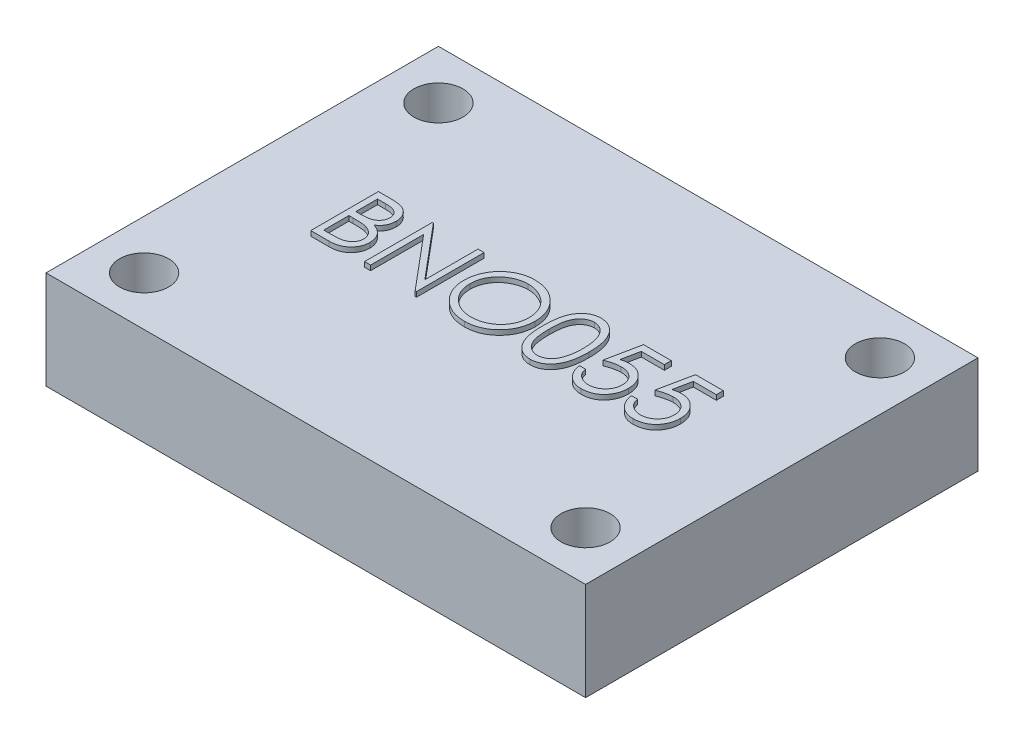
from build123d import *

# Parameters (mm, degrees)
SKETCH1_W           = 27.94
SKETCH1_H           = 20.32
SKETCH1_R           = 1.27
BOSS_EXTRUDE1_DEPTH = 5.08
BOSS_EXTRUDE2_DEPTH = 0.254


with BuildPart() as part:
    # Sketch1 → Boss-Extrude1 (new body)
    with BuildSketch(Plane(origin=(0, 0, 0), x_dir=(1, 0, 0), z_dir=(0, 1, 0))):
        Rectangle(SKETCH1_W, SKETCH1_H)
        with Locations((-11.43, 7.62)):
            Circle(SKETCH1_R, mode=Mode.SUBTRACT)
        with Locations((11.43, 7.62)):
            Circle(SKETCH1_R, mode=Mode.SUBTRACT)
        with Locations((11.43, -7.62)):
            Circle(SKETCH1_R, mode=Mode.SUBTRACT)
        with Locations((-11.43, -7.62)):
            Circle(SKETCH1_R, mode=Mode.SUBTRACT)
    extrude(amount=-BOSS_EXTRUDE1_DEPTH)

    # Sketch2 → Boss-Extrude2 (add)
    with BuildSketch(Plane(origin=(0, 0, 0), x_dir=(1, 0, 0), z_dir=(0, 1, 0))):
        with BuildLine():
            Line((-8.758801587, 1.83922598), (-8.075908959, 1.83922598))
            add(Edge.make_bspline(
                [(-8.075908959, 1.83922598), (-8.042480481, 1.83905023), (-7.97768777, 1.838709582), (-7.883468328, 1.83342645), (-7.795219518, 1.826222781), (-7.712915745, 1.814792688), (-7.636595043, 1.801000911), (-7.566027406, 1.784299095), (-7.501437233, 1.764272481), (-7.424324497, 1.7324262), (-7.336403836, 1.685103031), (-7.241205443, 1.615174466), (-7.159801204, 1.529642003), (-7.089614887, 1.433159348), (-7.033813767, 1.327023576), (-6.99344447, 1.213764387), (-6.967886595, 1.094842645), (-6.96525816, 1.013199467), (-6.963929792, 0.97193832)],
                knots=[0, 0, 0, 0, 0.00010027, 0.000194349, 0.000283026, 0.000365821, 0.000443519, 0.000515622, 0.000583254, 0.00064614, 0.000765662, 0.000881909, 0.000998927, 0.001118415, 0.001238844, 0.00135727, 0.001478274, 0.001601912, 0.001601912, 0.001601912, 0.001601912], degree=3))
            add(Edge.make_bspline(
                [(-6.963929792, 0.97193832), (-6.96502301, 0.933285764), (-6.967171288, 0.857329847), (-6.987714047, 0.746235738), (-7.019874716, 0.640484519), (-7.064579965, 0.540462134), (-7.122681961, 0.44842852), (-7.19154028, 0.363641254), (-7.274617082, 0.289690197), (-7.336860322, 0.248347295), (-7.368477068, 0.227346974)],
                knots=[0, 0, 0, 0, 0.000115857, 0.00022767, 0.000337672, 0.000446877, 0.000555233, 0.000663318, 0.000773539, 0.000887324, 0.000887324, 0.000887324, 0.000887324], degree=3))
            add(Edge.make_bspline(
                [(-7.368477068, 0.227346974), (-7.32871664, 0.212081975), (-7.252645093, 0.18287625), (-7.14795908, 0.131240786), (-7.057764235, 0.075078676), (-6.981367089, 0.013746826), (-6.916029434, -0.052361985), (-6.858976493, -0.124217099), (-6.810295119, -0.202755857), (-6.768582195, -0.287159393), (-6.736033439, -0.376565861), (-6.711657535, -0.470136637), (-6.697690086, -0.567536192), (-6.695702444, -0.633821572), (-6.694699023, -0.667284437)],
                knots=[0, 0, 0, 0, 0.000127722, 0.000244363, 0.000349599, 0.000445847, 0.000537565, 0.000627901, 0.000720503, 0.000814257, 0.000909859, 0.001005428, 0.001103887, 0.001204268, 0.001204268, 0.001204268, 0.001204268], degree=3))
            add(Edge.make_bspline(
                [(-6.694699023, -0.667284437), (-6.695675869, -0.701451309), (-6.697597841, -0.768675587), (-6.711777813, -0.867430721), (-6.73578692, -0.961805668), (-6.768858066, -1.052410851), (-6.81202038, -1.139070985), (-6.864548345, -1.221884249), (-6.927179908, -1.30001858), (-6.997242777, -1.374342203), (-7.076504923, -1.44116999), (-7.162020678, -1.500685697), (-7.254866998, -1.549631759), (-7.353518992, -1.590747781), (-7.459083308, -1.622154979), (-7.571085915, -1.644127553), (-7.689430217, -1.65893259), (-7.770639968, -1.660149795), (-7.812287164, -1.66077402)],
                knots=[0, 0, 0, 0, 0.000102481, 0.000201635, 0.000298562, 0.000394165, 0.000490425, 0.000588455, 0.000687769, 0.000790423, 0.000894381, 0.000998232, 0.001102369, 0.001208616, 0.001318415, 0.001432129, 0.001550749, 0.00167562, 0.00167562, 0.00167562, 0.00167562], degree=3))
            Line((-7.812287164, -1.66077402), (-8.758801587, -1.66077402))
            Line((-8.758801587, -1.66077402), (-8.758801587, 1.83922598))
        make_face()
        with BuildLine():
            Line((-8.444699023, 1.480251621), (-8.444699023, 0.358456749))
            Line((-8.444699023, 0.358456749), (-8.233661363, 0.358456749))
            add(Edge.make_bspline(
                [(-8.233661363, 0.358456749), (-8.202812567, 0.358856672), (-8.143206408, 0.359629405), (-8.056886511, 0.361842922), (-7.976761493, 0.368040965), (-7.90296966, 0.374237228), (-7.835627216, 0.384311815), (-7.774883355, 0.396303938), (-7.719784758, 0.408986843), (-7.656245212, 0.43055633), (-7.584172264, 0.462434005), (-7.50733916, 0.511905841), (-7.43960469, 0.570830195), (-7.382407502, 0.638821156), (-7.335596032, 0.713687342), (-7.303082317, 0.794234223), (-7.281035032, 0.878454355), (-7.279043501, 0.936272607), (-7.278032356, 0.965628224)],
                knots=[0, 0, 0, 0, 9.2559e-05, 0.000178842, 0.000258967, 0.000333616, 0.000400942, 0.000463093, 0.000519379, 0.000570374, 0.000664201, 0.000755025, 0.000843472, 0.000932526, 0.001020669, 0.001107124, 0.001192318, 0.001280185, 0.001280185, 0.001280185, 0.001280185], degree=3))
            add(Edge.make_bspline(
                [(-7.278032356, 0.965628224), (-7.278558536, 0.985053995), (-7.279590696, 1.023159767), (-7.288043999, 1.078709121), (-7.302411573, 1.130952874), (-7.320865866, 1.180606984), (-7.346654555, 1.226118834), (-7.377018019, 1.26906203), (-7.413703709, 1.307974149), (-7.455461021, 1.344343647), (-7.503469644, 1.376588175), (-7.557700936, 1.404828938), (-7.618888613, 1.427569715), (-7.686001468, 1.447485867), (-7.760072556, 1.461474161), (-7.840247109, 1.473127549), (-7.927181828, 1.479060291), (-7.987326931, 1.479845653), (-8.018416972, 1.480251621)],
                knots=[0, 0, 0, 0, 5.8261e-05, 0.000114285, 0.000168029, 0.000220632, 0.000272728, 0.000324483, 0.000378062, 0.000432741, 0.000490301, 0.000551137, 0.000615721, 0.000685833, 0.000760908, 0.00084162, 0.000928788, 0.00102206, 0.00102206, 0.00102206, 0.00102206], degree=3))
            Line((-8.018416972, 1.480251621), (-8.444699023, 1.480251621))
        make_face(mode=Mode.SUBTRACT)
        with BuildLine():
            Line((-8.444699023, -0.00051761), (-8.444699023, -1.301799661))
            Line((-8.444699023, -1.301799661), (-7.997383318, -1.301799661))
            add(Edge.make_bspline(
                [(-7.997383318, -1.301799661), (-7.965364392, -1.301415914), (-7.903652133, -1.300676291), (-7.814550903, -1.298261737), (-7.731967799, -1.292769461), (-7.656279664, -1.284123611), (-7.586669211, -1.274745162), (-7.523971508, -1.262133881), (-7.467678314, -1.247684921), (-7.402404007, -1.225350748), (-7.328900498, -1.190654277), (-7.249689642, -1.138340051), (-7.179263424, -1.076016743), (-7.119458165, -1.003885829), (-7.070445176, -0.925454502), (-7.034789721, -0.842309152), (-7.012798864, -0.755823625), (-7.010136695, -0.696856912), (-7.008801587, -0.667284437)],
                knots=[0, 0, 0, 0, 9.6064e-05, 0.000185151, 0.000267373, 0.000344257, 0.000413665, 0.000478015, 0.000536005, 0.000587888, 0.000684801, 0.000778918, 0.000871787, 0.000965866, 0.001059062, 0.00114827, 0.001236355, 0.001324974, 0.001324974, 0.001324974, 0.001324974], degree=3))
            add(Edge.make_bspline(
                [(-7.008801587, -0.667284437), (-7.009077691, -0.648791096), (-7.009625446, -0.612102714), (-7.017886061, -0.558186895), (-7.029899931, -0.505961022), (-7.045431365, -0.455283281), (-7.068050832, -0.407069905), (-7.094457377, -0.360367345), (-7.125418779, -0.315113866), (-7.173662945, -0.257901613), (-7.243834929, -0.1919846), (-7.343541705, -0.127447097), (-7.456914002, -0.07539929), (-7.539141495, -0.053299814), (-7.581618093, -0.041883796)],
                knots=[0, 0, 0, 0, 5.5429e-05, 0.000109963, 0.000163198, 0.000216191, 0.000268588, 0.000322593, 0.000377046, 0.000432793, 0.000546889, 0.000664343, 0.000787646, 0.000919405, 0.000919405, 0.000919405, 0.000919405], degree=3))
            add(Edge.make_bspline(
                [(-7.581618093, -0.041883796), (-7.598647189, -0.038428712), (-7.635569782, -0.030937377), (-7.695777362, -0.023029674), (-7.764513231, -0.015984614), (-7.841936108, -0.010773456), (-7.928143949, -0.005386912), (-8.023320868, -0.003292091), (-8.127078183, -0.000792831), (-8.199070555, -0.000611697), (-8.23646585, -0.00051761)],
                knots=[0, 0, 0, 0, 5.2115e-05, 0.000112995, 0.000182062, 0.000259389, 0.000345767, 0.00044116, 0.000544948, 0.000657129, 0.000657129, 0.000657129, 0.000657129], degree=3))
            Line((-8.23646585, -0.00051761), (-8.444699023, -0.00051761))
        make_face(mode=Mode.SUBTRACT)
        Polygon((-5.976750305, -1.66077402), (-5.976750305, 1.83922598), (-5.910844856, 1.83922598), (-3.598545177, -0.915481552), (-3.598545177, 1.83922598), (-3.284442613, 1.83922598), (-3.284442613, -1.66077402), (-3.355957036, -1.66077402), (-5.662647741, 1.087623416), (-5.662647741, -1.66077402), align=None)
        with BuildLine():
            add(Edge.make_bspline(
                [(-0.749186202, 1.92896957), (-0.684378096, 1.92732809), (-0.557089629, 1.924104089), (-0.370014732, 1.899424986), (-0.191419636, 1.856729596), (-0.019849498, 1.799866613), (0.142643479, 1.724012228), (0.297282371, 1.63232708), (0.443699245, 1.523850621), (0.579920627, 1.399421394), (0.704577577, 1.26403794), (0.814403463, 1.11956003), (0.906445757, 0.966861228), (0.982031544, 0.806400397), (1.041330154, 0.638540429), (1.082249198, 0.462386426), (1.108387348, 0.279079736), (1.111443125, 0.154052872), (1.112993285, 0.090628224)],
                knots=[0, 0, 0, 0, 0.000194393, 0.000381804, 0.00056479, 0.000744601, 0.000923091, 0.001101652, 0.001283106, 0.001468738, 0.001654324, 0.001834514, 0.002012231, 0.002188181, 0.002365797, 0.002545211, 0.002729936, 0.002920126, 0.002920126, 0.002920126, 0.002920126], degree=3))
            add(Edge.make_bspline(
                [(1.112993285, 0.090628224), (1.111443352, 0.027670777), (1.108388256, -0.096425643), (1.082219478, -0.278569087), (1.041178478, -0.453659784), (0.982582212, -0.621405437), (0.907356734, -0.781983), (0.814701563, -0.934969954), (0.705560352, -1.080416453), (0.581353501, -1.216729118), (0.445952459, -1.341726589), (0.300722192, -1.450645464), (0.148928872, -1.544369589), (-0.011380836, -1.619153263), (-0.178080873, -1.678925183), (-0.352663196, -1.719677813), (-0.53430975, -1.745964857), (-0.658180754, -1.748983373), (-0.72114133, -1.75051761)],
                knots=[0, 0, 0, 0, 0.000188789, 0.000372126, 0.000550857, 0.00072758, 0.000904164, 0.001081881, 0.001263191, 0.001448823, 0.00163441, 0.001815159, 0.001992641, 0.002168591, 0.002344885, 0.002522934, 0.002705576, 0.002894365, 0.002894365, 0.002894365, 0.002894365], degree=3))
            add(Edge.make_bspline(
                [(-0.72114133, -1.75051761), (-0.784565649, -1.748968223), (-0.909591865, -1.745913969), (-1.093128901, -1.719732564), (-1.269406645, -1.67879126), (-1.437920996, -1.620281824), (-1.598765925, -1.544664593), (-1.752256008, -1.452460214), (-1.897775155, -1.343053073), (-2.034116902, -1.218886499), (-2.1588661, -1.083714947), (-2.267625476, -0.938880691), (-2.359850589, -0.787225235), (-2.435213922, -0.628327711), (-2.494878381, -0.462956268), (-2.535583199, -0.290007791), (-2.561919151, -0.110468285), (-2.564953998, 0.011774614), (-2.566493895, 0.073801301)],
                knots=[0, 0, 0, 0, 0.00019019, 0.000374915, 0.000555011, 0.000732396, 0.00090898, 0.001087298, 0.001268608, 0.00145424, 0.001639827, 0.001819595, 0.001996712, 0.002171394, 0.002346367, 0.002523053, 0.002703612, 0.002889599, 0.002889599, 0.002889599, 0.002889599], degree=3))
            add(Edge.make_bspline(
                [(-2.566493895, 0.073801301), (-2.565959259, 0.11543397), (-2.564896733, 0.198174093), (-2.55210504, 0.321040693), (-2.533543339, 0.441931351), (-2.506941427, 0.560502299), (-2.47214976, 0.676463284), (-2.431097732, 0.790614047), (-2.380957887, 0.90179777), (-2.324277239, 1.010541162), (-2.261015431, 1.115149068), (-2.191139681, 1.214028651), (-2.117104313, 1.308009648), (-2.035940919, 1.394656652), (-1.950324474, 1.476490308), (-1.858866096, 1.552253025), (-1.762123851, 1.622627976), (-1.659681472, 1.686048317), (-1.554063197, 1.743407452), (-1.445186419, 1.792629303), (-1.334529848, 1.834875364), (-1.2215752, 1.869116189), (-1.106622428, 1.896148225), (-0.989420643, 1.914555579), (-0.870063217, 1.927379897), (-0.789651898, 1.928437399), (-0.749186202, 1.92896957)],
                knots=[0, 0, 0, 0, 0.000124849, 0.000248123, 0.000370193, 0.00049164, 0.000612319, 0.000733199, 0.000855287, 0.000977905, 0.001100913, 0.001221706, 0.001340948, 0.001459521, 0.001577551, 0.001696047, 0.001815534, 0.001936153, 0.002057243, 0.002175846, 0.002294342, 0.002412335, 0.002529682, 0.00264829, 0.002768075, 0.00288942, 0.00288942, 0.00288942, 0.00288942], degree=3))
        make_face()
        with BuildLine():
            add(Edge.make_bspline(
                [(-0.733761523, 1.569995211), (-0.766976156, 1.569590321), (-0.833087889, 1.568784411), (-0.931372426, 1.558168695), (-1.028364359, 1.543038806), (-1.124083722, 1.521457285), (-1.218130011, 1.492053233), (-1.311379852, 1.458212325), (-1.402982906, 1.416991234), (-1.492636764, 1.37041853), (-1.579551839, 1.318869609), (-1.66156454, 1.261897842), (-1.738887184, 1.200839287), (-1.811330451, 1.13555145), (-1.878681623, 1.065701848), (-1.942266325, 0.992349412), (-1.999535906, 0.913397521), (-2.052021483, 0.830987114), (-2.098989323, 0.745225533), (-2.140754678, 0.657015671), (-2.174918687, 0.565637984), (-2.202781063, 0.472083826), (-2.225880874, 0.376501367), (-2.240514798, 0.278165518), (-2.251247158, 0.177570406), (-2.252007003, 0.109588552), (-2.25239133, 0.075203544)],
                knots=[0, 0, 0, 0, 9.9599e-05, 0.000198245, 0.000296222, 0.00039402, 0.00049227, 0.000591646, 0.000691452, 0.000793368, 0.000894612, 0.000994383, 0.001092713, 0.00119001, 0.001286696, 0.001383657, 0.001480979, 0.001579008, 0.001676595, 0.001774142, 0.001871547, 0.001968922, 0.002066879, 0.00216624, 0.00226698, 0.002370083, 0.002370083, 0.002370083, 0.002370083], degree=3))
            add(Edge.make_bspline(
                [(-2.25239133, 0.075203544), (-2.251116469, 0.024641323), (-2.248608421, -0.074830207), (-2.226650851, -0.220598351), (-2.192828876, -0.360686637), (-2.14297151, -0.494328546), (-2.080620895, -0.622672829), (-2.003594005, -0.744580934), (-1.912334919, -0.860085808), (-1.808671393, -0.968381077), (-1.695348686, -1.067226882), (-1.575015956, -1.15399029), (-1.448962349, -1.22740054), (-1.316859146, -1.287205612), (-1.179411607, -1.33459535), (-1.035734056, -1.367073981), (-0.886783596, -1.388449437), (-0.785252941, -1.390502193), (-0.733761523, -1.391543251)],
                knots=[0, 0, 0, 0, 0.000151605, 0.000298253, 0.000441263, 0.000583229, 0.000725274, 0.000868635, 0.001014928, 0.001166177, 0.001317744, 0.00146543, 0.001610576, 0.001754594, 0.001899821, 0.002045914, 0.002195936, 0.002350312, 0.002350312, 0.002350312, 0.002350312], degree=3))
            add(Edge.make_bspline(
                [(-0.733761523, -1.391543251), (-0.699152021, -1.391067746), (-0.630510985, -1.390124678), (-0.528415462, -1.380626002), (-0.428159251, -1.365394132), (-0.329882971, -1.343463477), (-0.233698159, -1.31601627), (-0.139203356, -1.283408542), (-0.047405066, -1.242727338), (0.042854772, -1.197779387), (0.129251013, -1.146539229), (0.211726546, -1.09150108), (0.288202526, -1.030532459), (0.360591597, -0.966214646), (0.428219286, -0.897250799), (0.49062827, -0.823730577), (0.547608402, -0.74518992), (0.600074049, -0.662904514), (0.646877312, -0.576908261), (0.687656411, -0.488378583), (0.722252527, -0.397533474), (0.750181031, -0.304241902), (0.772066493, -0.208681054), (0.787146413, -0.110722975), (0.797694852, -0.010563633), (0.798489929, 0.057180223), (0.798890721, 0.091329345)],
                knots=[0, 0, 0, 0, 0.000103804, 0.000205874, 0.000307314, 0.000407849, 0.000507719, 0.000607281, 0.000707445, 0.000808723, 0.000909609, 0.001008589, 0.001105934, 0.001202762, 0.001298946, 0.001395452, 0.001491794, 0.001589823, 0.001688026, 0.001785277, 0.001882027, 0.001979402, 0.0020772, 0.002175869, 0.002276609, 0.002379011, 0.002379011, 0.002379011, 0.002379011], degree=3))
            add(Edge.make_bspline(
                [(0.798890721, 0.091329345), (0.798489608, 0.12524485), (0.797693926, 0.1925225), (0.787151452, 0.291983318), (0.772050561, 0.38923653), (0.750287853, 0.483900333), (0.7222377, 0.575998858), (0.687650369, 0.665445605), (0.64686507, 0.752573801), (0.600056845, 0.837168098), (0.547441022, 0.918342836), (0.489946779, 0.995945248), (0.42658143, 1.068517989), (0.359155406, 1.137852683), (0.28598452, 1.202470573), (0.207400226, 1.262393094), (0.124356548, 1.319066368), (0.036429313, 1.37019193), (-0.054314641, 1.417406162), (-0.147428599, 1.457857166), (-0.241857698, 1.492229285), (-0.337361811, 1.52154625), (-0.434744789, 1.54295428), (-0.533348618, 1.55818233), (-0.633036876, 1.568780716), (-0.700080096, 1.569589095), (-0.733761523, 1.569995211)],
                knots=[0, 0, 0, 0, 0.000101701, 0.000201743, 0.00029972, 0.000396835, 0.000492868, 0.000588308, 0.000684288, 0.000781261, 0.000878109, 0.000974304, 0.001070733, 0.001166917, 0.001264269, 0.001363274, 0.001463228, 0.001565678, 0.001668217, 0.001769947, 0.001869982, 0.001969573, 0.002069423, 0.002168785, 0.002268827, 0.002369827, 0.002369827, 0.002369827, 0.002369827], degree=3))
        make_face(mode=Mode.SUBTRACT)
        with BuildLine():
            add(Edge.make_bspline(
                [(1.516839439, 0.087823736), (1.517167457, 0.143921124), (1.517804637, 0.252891108), (1.524893058, 0.41167575), (1.5366684, 0.560636039), (1.552805773, 0.699779106), (1.572443753, 0.82914087), (1.59865924, 0.948375627), (1.628472042, 1.058035234), (1.663024488, 1.158477282), (1.702012277, 1.251054985), (1.744446538, 1.337480187), (1.792011332, 1.417622119), (1.841988245, 1.492759909), (1.896400317, 1.561663604), (1.953699107, 1.625306267), (2.016120984, 1.682217017), (2.081543992, 1.734063319), (2.150560456, 1.779512791), (2.221203123, 1.81954553), (2.293958228, 1.853745397), (2.369024411, 1.880635833), (2.445726969, 1.90284668), (2.524334036, 1.918035627), (2.6049754, 1.927592536), (2.659406835, 1.928506204), (2.687011714, 1.92896957)],
                knots=[0, 0, 0, 0, 0.000168282, 0.000326891, 0.000476705, 0.00061646, 0.000747059, 0.00086904, 0.000982494, 0.001087814, 0.001187428, 0.001283689, 0.001376399, 0.001466822, 0.001554203, 0.001639568, 0.001723424, 0.001807301, 0.001889751, 0.001971063, 0.002050735, 0.002130583, 0.002210036, 0.002290062, 0.002370508, 0.002453288, 0.002453288, 0.002453288, 0.002453288], degree=3))
            add(Edge.make_bspline(
                [(2.687011714, 1.92896957), (2.714847193, 1.928481755), (2.770203202, 1.927511644), (2.852043577, 1.918187701), (2.931993259, 1.902716578), (3.009711397, 1.880795603), (3.085836384, 1.853599927), (3.159772792, 1.81951281), (3.231979873, 1.779833942), (3.301310161, 1.733210065), (3.368524776, 1.681227789), (3.431972739, 1.62246512), (3.491659825, 1.557515401), (3.54833513, 1.487073537), (3.600390728, 1.409788452), (3.64996416, 1.327004342), (3.694336196, 1.237273477), (3.737070871, 1.14209301), (3.773957858, 1.038829351), (3.807224103, 0.92806459), (3.834103071, 0.808490403), (3.856492344, 0.680734158), (3.87383724, 0.544326675), (3.886469882, 0.399560359), (3.893142967, 0.246339969), (3.894399668, 0.14158212), (3.895044567, 0.087823736)],
                knots=[0, 0, 0, 0, 8.3481e-05, 0.000166017, 0.000246731, 0.000327534, 0.000408041, 0.000488986, 0.000571522, 0.000654944, 0.000739373, 0.000826202, 0.000914021, 0.001003809, 0.001097153, 0.001193347, 0.001293057, 0.001397277, 0.001506176, 0.001621751, 0.001744038, 0.001873599, 0.002010742, 0.002156422, 0.002309427, 0.002470709, 0.002470709, 0.002470709, 0.002470709], degree=3))
            add(Edge.make_bspline(
                [(3.895044567, 0.087823736), (3.894392982, 0.034299828), (3.893123396, -0.069989323), (3.88654469, -0.222520299), (3.873586059, -0.366518342), (3.85737607, -0.502328804), (3.834925107, -0.629386423), (3.807319941, -0.748130872), (3.776669618, -0.859074943), (3.738834824, -0.961309755), (3.697424114, -1.056261478), (3.652368918, -1.144928626), (3.604099091, -1.228094919), (3.551510346, -1.305094666), (3.495456933, -1.376473323), (3.434739144, -1.440970946), (3.371068559, -1.500141618), (3.303656144, -1.552793245), (3.233244592, -1.59887805), (3.161285515, -1.6400919), (3.086502132, -1.673324595), (3.010589179, -1.701859636), (2.932460813, -1.723660088), (2.852214423, -1.738733943), (2.770258187, -1.749305792), (2.714856621, -1.750112272), (2.687011714, -1.75051761)],
                knots=[0, 0, 0, 0, 0.000160581, 0.000312886, 0.000457868, 0.000594226, 0.000723097, 0.000844701, 0.000959884, 0.001068125, 0.001171421, 0.001270505, 0.001366343, 0.001459687, 0.001550023, 0.00163832, 0.001725149, 0.001810562, 0.001894568, 0.001977446, 0.00205903, 0.002139777, 0.00222058, 0.002301983, 0.002384599, 0.00246808, 0.00246808, 0.00246808, 0.00246808], degree=3))
            add(Edge.make_bspline(
                [(2.687011714, -1.75051761), (2.6594076, -1.750051254), (2.604977676, -1.749131692), (2.52432525, -1.739617961), (2.446042807, -1.724322458), (2.369744053, -1.702905854), (2.295037538, -1.676691017), (2.222941251, -1.642537334), (2.152653567, -1.603203265), (2.084362011, -1.558407843), (2.01934985, -1.50708616), (1.957251245, -1.450321871), (1.899626226, -1.38669846), (1.84599213, -1.317220537), (1.795018042, -1.242527295), (1.748128669, -1.161598922), (1.704757815, -1.074756311), (1.665114324, -0.9814384), (1.62996566, -0.880283473), (1.598917952, -0.770134294), (1.574403795, -0.650018658), (1.55342084, -0.520901291), (1.536496456, -0.38222736), (1.524942131, -0.233921582), (1.517800816, -0.076076373), (1.517165746, 0.032193401), (1.516839439, 0.087823736)],
                knots=[0, 0, 0, 0, 8.278e-05, 0.000163226, 0.000243252, 0.00032184, 0.00040079, 0.000480463, 0.00056082, 0.000642298, 0.000725191, 0.000809047, 0.000894412, 0.000982346, 0.001072188, 0.001165503, 0.001262704, 0.001363236, 0.001469448, 0.001583766, 0.001706286, 0.001836995, 0.001976138, 0.002125253, 0.002283161, 0.002450041, 0.002450041, 0.002450041, 0.002450041], degree=3))
        make_face()
        with BuildLine():
            add(Edge.make_bspline(
                [(1.830942003, 0.08922598), (1.83106145, 0.042477281), (1.831293273, -0.048252764), (1.837349474, -0.180096025), (1.845599706, -0.303066353), (1.856241003, -0.41731989), (1.872043952, -0.522469902), (1.889750739, -0.619239585), (1.911298829, -0.707116823), (1.936793847, -0.786704633), (1.965832944, -0.859353702), (1.997538807, -0.926954917), (2.03159953, -0.990306853), (2.069718681, -1.048840462), (2.111233744, -1.102746626), (2.155207003, -1.152979458), (2.203279587, -1.197776439), (2.26978333, -1.251503294), (2.357579804, -1.307022428), (2.46820026, -1.355368518), (2.581868711, -1.385750974), (2.659019961, -1.38961473), (2.697528541, -1.391543251)],
                knots=[0, 0, 0, 0, 0.000140231, 0.000272162, 0.000395845, 0.00050998, 0.000616273, 0.00071473, 0.000805025, 0.000887508, 0.000965234, 0.00103957, 0.001111417, 0.001180842, 0.001248855, 0.001315406, 0.001380877, 0.0014457, 0.001571746, 0.00169106, 0.001806864, 0.001922266, 0.001922266, 0.001922266, 0.001922266], degree=3))
            add(Edge.make_bspline(
                [(2.697528541, -1.391543251), (2.736286213, -1.38994547), (2.813721536, -1.386753207), (2.926855331, -1.35595447), (3.036685601, -1.30948493), (3.122757542, -1.254537425), (3.188240085, -1.202209095), (3.235157075, -1.157594447), (3.278219124, -1.10763858), (3.319061199, -1.053739284), (3.356520274, -0.9948668), (3.390583412, -0.931304224), (3.421666759, -0.862875047), (3.439375805, -0.815105307), (3.448429984, -0.790681873)],
                knots=[0, 0, 0, 0, 0.000116044, 0.000231848, 0.000349318, 0.000472837, 0.000536674, 0.000600645, 0.000666733, 0.000734322, 0.000803367, 0.000875831, 0.000950509, 0.001028633, 0.001028633, 0.001028633, 0.001028633], degree=3))
            add(Edge.make_bspline(
                [(3.448429984, -0.790681873), (3.458981751, -0.759452133), (3.480406365, -0.696042369), (3.50801814, -0.597678717), (3.529763539, -0.494475953), (3.549326904, -0.387050836), (3.56267996, -0.274611135), (3.573427774, -0.157504751), (3.579758461, -0.035643389), (3.580543212, 0.047151602), (3.580942003, 0.08922598)],
                knots=[0, 0, 0, 0, 9.8886e-05, 0.00020078, 0.000306259, 0.000415188, 0.00052824, 0.000645799, 0.000767957, 0.000894177, 0.000894177, 0.000894177, 0.000894177], degree=3))
            add(Edge.make_bspline(
                [(3.580942003, 0.08922598), (3.580391814, 0.131293553), (3.579315526, 0.213586717), (3.575201538, 0.334104898), (3.564577964, 0.448572659), (3.552778845, 0.557483132), (3.535381624, 0.660233434), (3.516623817, 0.75768374), (3.491422605, 0.848626764), (3.46450283, 0.934486346), (3.433692434, 1.014287001), (3.3997767, 1.088400787), (3.363554941, 1.157185512), (3.324212701, 1.220452453), (3.282217017, 1.278484996), (3.236459468, 1.330119591), (3.188755095, 1.376956559), (3.12193791, 1.430419128), (3.03446362, 1.484930823), (2.925617973, 1.535096583), (2.812347328, 1.563904876), (2.735773874, 1.567966563), (2.697528541, 1.569995211)],
                knots=[0, 0, 0, 0, 0.000126219, 0.000246912, 0.000361616, 0.00047102, 0.00057545, 0.000674176, 0.000768567, 0.000858368, 0.000944043, 0.001024988, 0.001102772, 0.001177091, 0.00124833, 0.001317386, 0.001383826, 0.001448649, 0.001573728, 0.001692043, 0.001806995, 0.001921698, 0.001921698, 0.001921698, 0.001921698], degree=3))
            add(Edge.make_bspline(
                [(2.697528541, 1.569995211), (2.658817949, 1.567963764), (2.581326244, 1.56389717), (2.466878289, 1.535203916), (2.357173937, 1.485190951), (2.269930963, 1.430238578), (2.203067176, 1.377900267), (2.155984483, 1.332513813), (2.11183831, 1.282867558), (2.07117061, 1.228465643), (2.033081327, 1.170000276), (1.998100315, 1.107011511), (1.966582985, 1.039180147), (1.937498449, 0.966563712), (1.911925661, 0.886982767), (1.890831697, 0.799213774), (1.871344644, 0.702751882), (1.857549375, 0.597032374), (1.84528562, 0.482750221), (1.837404272, 0.359472902), (1.831273014, 0.227408522), (1.83105455, 0.136209363), (1.830942003, 0.08922598)],
                knots=[0, 0, 0, 0, 0.000116101, 0.000232413, 0.000351368, 0.000476447, 0.000540832, 0.000605795, 0.000672346, 0.000739935, 0.00080936, 0.000881545, 0.00095588, 0.001033607, 0.001116089, 0.001206384, 0.001304286, 0.001411174, 0.001526077, 0.001649061, 0.001781692, 0.001922624, 0.001922624, 0.001922624, 0.001922624], degree=3))
        make_face(mode=Mode.SUBTRACT)
        with BuildLine():
            Line((6.40786508, 1.83922598), (6.40786508, 1.480251621))
            Line((6.40786508, 1.480251621), (5.217360272, 1.480251621))
            Line((5.217360272, 1.480251621), (5.028758509, 0.559678704))
            add(Edge.make_bspline(
                [(5.028758509, 0.559678704), (5.065814384, 0.569908976), (5.137604279, 0.58972851), (5.24356414, 0.61173428), (5.344156344, 0.624999724), (5.409431714, 0.626811035), (5.441018125, 0.627687518)],
                knots=[0, 0, 0, 0, 0.000115302, 0.000223379, 0.000324431, 0.000419176, 0.000419176, 0.000419176, 0.000419176], degree=3))
            add(Edge.make_bspline(
                [(5.441018125, 0.627687518), (5.480101864, 0.626841583), (5.556950262, 0.625178262), (5.669389209, 0.609206412), (5.776722102, 0.584066498), (5.878724472, 0.548945976), (5.975585023, 0.504036243), (6.066412584, 0.447936302), (6.152570497, 0.382402971), (6.232513091, 0.307057959), (6.305037399, 0.224136343), (6.368803389, 0.134978472), (6.422965979, 0.040450809), (6.466526734, -0.060349799), (6.501311068, -0.166308953), (6.524463063, -0.278541535), (6.539879772, -0.395989655), (6.541602159, -0.476294225), (6.542480464, -0.517244373)],
                knots=[0, 0, 0, 0, 0.00011719, 0.000230425, 0.000339944, 0.000447481, 0.000553499, 0.000659556, 0.000767111, 0.000877722, 0.000988528, 0.001097091, 0.001206056, 0.001314692, 0.001425996, 0.001539995, 0.001658004, 0.001780798, 0.001780798, 0.001780798, 0.001780798], degree=3))
            add(Edge.make_bspline(
                [(6.542480464, -0.517244373), (6.541815389, -0.545766593), (6.540494226, -0.60242558), (6.533775639, -0.686569781), (6.520839923, -0.768932614), (6.503472199, -0.849525006), (6.480929781, -0.928194378), (6.453640727, -1.005165906), (6.420244699, -1.079960513), (6.383613324, -1.153285908), (6.342366846, -1.223484415), (6.296588339, -1.289133402), (6.248222847, -1.351217683), (6.196181462, -1.409071416), (6.139980467, -1.462314434), (6.0803005, -1.511262716), (6.017617781, -1.556744046), (5.950962539, -1.596912241), (5.881820056, -1.633875197), (5.809191839, -1.664198735), (5.734731138, -1.691309263), (5.657366262, -1.71291879), (5.57727245, -1.729851345), (5.494317674, -1.741351945), (5.408937004, -1.749728383), (5.351061992, -1.75025274), (5.32182742, -1.75051761)],
                knots=[0, 0, 0, 0, 8.5583e-05, 0.000170009, 0.000253005, 0.000335518, 0.000417186, 0.000498352, 0.000580291, 0.000662755, 0.000744161, 0.000824288, 0.000902692, 0.000980133, 0.001057498, 0.001134702, 0.00121156, 0.001289599, 0.001368002, 0.001446531, 0.001525481, 0.001605609, 0.001687289, 0.001770875, 0.001856759, 0.001944425, 0.001944425, 0.001944425, 0.001944425], degree=3))
            add(Edge.make_bspline(
                [(5.32182742, -1.75051761), (5.286953239, -1.749826772), (5.218342408, -1.74846763), (5.117821841, -1.734249144), (5.021107235, -1.713885228), (4.928977134, -1.683248958), (4.84060587, -1.644861663), (4.757183153, -1.596345492), (4.676577377, -1.541366388), (4.60206534, -1.476486035), (4.532909226, -1.405570353), (4.471002718, -1.328612712), (4.415869141, -1.24688327), (4.368391394, -1.159985116), (4.327893373, -1.068146585), (4.296078384, -0.971023584), (4.270400029, -0.86912358), (4.259536609, -0.79897007), (4.254018926, -0.763338123)],
                knots=[0, 0, 0, 0, 0.000104552, 0.000205693, 0.000304023, 0.000400691, 0.00049644, 0.000592535, 0.000689779, 0.000788716, 0.000888377, 0.000986596, 0.001084603, 0.001183757, 0.001283279, 0.001385267, 0.001490017, 0.001598135, 0.001598135, 0.001598135, 0.001598135], degree=3))
            Line((4.254018926, -0.763338123), (4.56812149, -0.763338123))
            add(Edge.make_bspline(
                [(4.56812149, -0.763338123), (4.575850047, -0.796714575), (4.590704764, -0.86086597), (4.623310513, -0.950997311), (4.663176388, -1.031316535), (4.710580736, -1.102886118), (4.767130767, -1.165295115), (4.831660196, -1.220912177), (4.904007919, -1.271087307), (4.984401149, -1.312910074), (5.069214228, -1.348578827), (5.157981438, -1.372330522), (5.248285784, -1.389031415), (5.309364155, -1.390703176), (5.340056586, -1.391543251)],
                knots=[0, 0, 0, 0, 0.000102709, 0.000197412, 0.000286774, 0.000371169, 0.000454082, 0.000538572, 0.000626283, 0.000717552, 0.000809994, 0.00090168, 0.00099274, 0.001084718, 0.001084718, 0.001084718, 0.001084718], degree=3))
            add(Edge.make_bspline(
                [(5.340056586, -1.391543251), (5.370015031, -1.390722473), (5.429003453, -1.389106354), (5.515814839, -1.376667342), (5.599627714, -1.357509771), (5.67961507, -1.328839916), (5.75717661, -1.293995198), (5.83035038, -1.249280122), (5.901253258, -1.197820103), (5.967681391, -1.138863473), (6.02852084, -1.073893779), (6.082276962, -1.004416385), (6.127053875, -0.930299539), (6.164787984, -0.852826386), (6.193441283, -0.771147829), (6.213882264, -0.685646654), (6.225885323, -0.596111673), (6.227536503, -0.535042364), (6.2283779, -0.503923058)],
                knots=[0, 0, 0, 0, 8.9842e-05, 0.0001769, 0.000262612, 0.000347317, 0.000431396, 0.000517249, 0.000604055, 0.000693954, 0.000783242, 0.000870748, 0.000956963, 0.001042571, 0.001128832, 0.00121607, 0.001305907, 0.001399251, 0.001399251, 0.001399251, 0.001399251], degree=3))
            add(Edge.make_bspline(
                [(6.2283779, -0.503923058), (6.227719421, -0.475847307), (6.226430541, -0.420893018), (6.215899971, -0.340493811), (6.197582998, -0.264420769), (6.172159118, -0.192306535), (6.139879611, -0.124083093), (6.100433298, -0.059680033), (6.0530799, 5.3801e-05), (5.998988012, 0.055146354), (5.939729971, 0.105991229), (5.874286228, 0.149335316), (5.804026301, 0.185799233), (5.729796702, 0.217267232), (5.649831803, 0.239867977), (5.565715171, 0.256835862), (5.476538463, 0.266651225), (5.415567775, 0.268013114), (5.384227259, 0.26871316)],
                knots=[0, 0, 0, 0, 8.4208e-05, 0.000164824, 0.000242709, 0.000318547, 0.000393815, 0.000468731, 0.000544614, 0.00062196, 0.000700062, 0.000778428, 0.000856831, 0.000937299, 0.001019835, 0.001105635, 0.00119452, 0.001288536, 0.001288536, 0.001288536, 0.001288536], degree=3))
            add(Edge.make_bspline(
                [(5.384227259, 0.26871316), (5.35709833, 0.268132568), (5.301083975, 0.266933795), (5.215161148, 0.258107298), (5.124869425, 0.243868004), (5.03055493, 0.224281756), (4.931934422, 0.198650679), (4.829216021, 0.167936179), (4.722183754, 0.13121418), (4.65006603, 0.103481966), (4.612993285, 0.08922598)],
                knots=[0, 0, 0, 0, 8.1378e-05, 0.000168026, 0.000258858, 0.000355524, 0.000456875, 0.000564457, 0.000677092, 0.000796243, 0.000796243, 0.000796243, 0.000796243], degree=3))
            Line((4.612993285, 0.08922598), (4.971967644, 1.83922598))
            Line((4.971967644, 1.83922598), (6.40786508, 1.83922598))
        make_face()
        with BuildLine():
            Line((9.100172772, 1.83922598), (9.100172772, 1.480251621))
            Line((9.100172772, 1.480251621), (7.909667964, 1.480251621))
            Line((7.909667964, 1.480251621), (7.721066202, 0.559678704))
            add(Edge.make_bspline(
                [(7.721066202, 0.559678704), (7.758122076, 0.569908976), (7.829911972, 0.58972851), (7.935871833, 0.61173428), (8.036464036, 0.624999724), (8.101739407, 0.626811035), (8.133325817, 0.627687518)],
                knots=[0, 0, 0, 0, 0.000115302, 0.000223379, 0.000324431, 0.000419176, 0.000419176, 0.000419176, 0.000419176], degree=3))
            add(Edge.make_bspline(
                [(8.133325817, 0.627687518), (8.172409557, 0.626841583), (8.249257954, 0.625178262), (8.361696901, 0.609206412), (8.469029794, 0.584066498), (8.571032164, 0.548945976), (8.667892715, 0.504036243), (8.758720276, 0.447936302), (8.844878189, 0.382402971), (8.924820783, 0.307057959), (8.997345092, 0.224136343), (9.061111081, 0.134978472), (9.115273672, 0.040450809), (9.158834426, -0.060349799), (9.193618761, -0.166308953), (9.216770756, -0.278541535), (9.232187465, -0.395989655), (9.233909851, -0.476294225), (9.234788157, -0.517244373)],
                knots=[0, 0, 0, 0, 0.00011719, 0.000230425, 0.000339944, 0.000447481, 0.000553499, 0.000659556, 0.000767111, 0.000877722, 0.000988528, 0.001097091, 0.001206056, 0.001314692, 0.001425996, 0.001539995, 0.001658004, 0.001780798, 0.001780798, 0.001780798, 0.001780798], degree=3))
            add(Edge.make_bspline(
                [(9.234788157, -0.517244373), (9.234123081, -0.545766593), (9.232801919, -0.60242558), (9.226083331, -0.686569781), (9.213147615, -0.768932614), (9.195779891, -0.849525006), (9.173237473, -0.928194378), (9.145948419, -1.005165906), (9.112552392, -1.079960513), (9.075921016, -1.153285908), (9.034674538, -1.223484415), (8.988896031, -1.289133402), (8.94053054, -1.351217683), (8.888489154, -1.409071416), (8.832288159, -1.462314434), (8.772608192, -1.511262716), (8.709925473, -1.556744046), (8.643270231, -1.596912241), (8.574127748, -1.633875197), (8.501499531, -1.664198735), (8.42703883, -1.691309263), (8.349673955, -1.71291879), (8.269580142, -1.729851345), (8.186625367, -1.741351945), (8.101244697, -1.749728383), (8.043369684, -1.75025274), (8.014135112, -1.75051761)],
                knots=[0, 0, 0, 0, 8.5583e-05, 0.000170009, 0.000253005, 0.000335518, 0.000417186, 0.000498352, 0.000580291, 0.000662755, 0.000744161, 0.000824288, 0.000902692, 0.000980133, 0.001057498, 0.001134702, 0.00121156, 0.001289599, 0.001368002, 0.001446531, 0.001525481, 0.001605609, 0.001687289, 0.001770875, 0.001856759, 0.001944425, 0.001944425, 0.001944425, 0.001944425], degree=3))
            add(Edge.make_bspline(
                [(8.014135112, -1.75051761), (7.979260931, -1.749826772), (7.9106501, -1.74846763), (7.810129533, -1.734249144), (7.713414928, -1.713885228), (7.621284826, -1.683248958), (7.532913563, -1.644861663), (7.449490845, -1.596345492), (7.368885069, -1.541366388), (7.294373032, -1.476486035), (7.225216919, -1.405570353), (7.16331041, -1.328612712), (7.108176833, -1.24688327), (7.060699086, -1.159985116), (7.020201065, -1.068146585), (6.988386077, -0.971023584), (6.962707722, -0.86912358), (6.951844301, -0.79897007), (6.946326618, -0.763338123)],
                knots=[0, 0, 0, 0, 0.000104552, 0.000205693, 0.000304023, 0.000400691, 0.00049644, 0.000592535, 0.000689779, 0.000788716, 0.000888377, 0.000986596, 0.001084603, 0.001183757, 0.001283279, 0.001385267, 0.001490017, 0.001598135, 0.001598135, 0.001598135, 0.001598135], degree=3))
            Line((6.946326618, -0.763338123), (7.260429182, -0.763338123))
            add(Edge.make_bspline(
                [(7.260429182, -0.763338123), (7.26815774, -0.796714575), (7.283012456, -0.86086597), (7.315618205, -0.950997311), (7.35548408, -1.031316535), (7.402888429, -1.102886118), (7.459438459, -1.165295115), (7.523967888, -1.220912177), (7.596315611, -1.271087307), (7.676708841, -1.312910074), (7.76152192, -1.348578827), (7.85028913, -1.372330522), (7.940593477, -1.389031415), (8.001671847, -1.390703176), (8.032364278, -1.391543251)],
                knots=[0, 0, 0, 0, 0.000102709, 0.000197412, 0.000286774, 0.000371169, 0.000454082, 0.000538572, 0.000626283, 0.000717552, 0.000809994, 0.00090168, 0.00099274, 0.001084718, 0.001084718, 0.001084718, 0.001084718], degree=3))
            add(Edge.make_bspline(
                [(8.032364278, -1.391543251), (8.062322723, -1.390722473), (8.121311145, -1.389106354), (8.208122532, -1.376667342), (8.291935406, -1.357509771), (8.371922763, -1.328839916), (8.449484302, -1.293995198), (8.522658073, -1.249280122), (8.59356095, -1.197820103), (8.659989083, -1.138863473), (8.720828533, -1.073893779), (8.774584654, -1.004416385), (8.819361567, -0.930299539), (8.857095676, -0.852826386), (8.885748975, -0.771147829), (8.906189956, -0.685646654), (8.918193015, -0.596111673), (8.919844195, -0.535042364), (8.920685593, -0.503923058)],
                knots=[0, 0, 0, 0, 8.9842e-05, 0.0001769, 0.000262612, 0.000347317, 0.000431396, 0.000517249, 0.000604055, 0.000693954, 0.000783242, 0.000870748, 0.000956963, 0.001042571, 0.001128832, 0.00121607, 0.001305907, 0.001399251, 0.001399251, 0.001399251, 0.001399251], degree=3))
            add(Edge.make_bspline(
                [(8.920685593, -0.503923058), (8.920027113, -0.475847307), (8.918738233, -0.420893018), (8.908207663, -0.340493811), (8.889890691, -0.264420769), (8.864466811, -0.192306535), (8.832187303, -0.124083093), (8.792740991, -0.059680033), (8.745387593, 5.3801e-05), (8.691295704, 0.055146354), (8.632037663, 0.105991229), (8.566593921, 0.149335316), (8.496333994, 0.185799233), (8.422104394, 0.217267232), (8.342139496, 0.239867977), (8.258022863, 0.256835862), (8.168846155, 0.266651225), (8.107875467, 0.268013114), (8.076534952, 0.26871316)],
                knots=[0, 0, 0, 0, 8.4208e-05, 0.000164824, 0.000242709, 0.000318547, 0.000393815, 0.000468731, 0.000544614, 0.00062196, 0.000700062, 0.000778428, 0.000856831, 0.000937299, 0.001019835, 0.001105635, 0.00119452, 0.001288536, 0.001288536, 0.001288536, 0.001288536], degree=3))
            add(Edge.make_bspline(
                [(8.076534952, 0.26871316), (8.049406023, 0.268132568), (7.993391667, 0.266933795), (7.907468841, 0.258107298), (7.817177118, 0.243868004), (7.722862622, 0.224281756), (7.624242114, 0.198650679), (7.521523713, 0.167936179), (7.414491447, 0.13121418), (7.342373722, 0.103481966), (7.305300977, 0.08922598)],
                knots=[0, 0, 0, 0, 8.1378e-05, 0.000168026, 0.000258858, 0.000355524, 0.000456875, 0.000564457, 0.000677092, 0.000796243, 0.000796243, 0.000796243, 0.000796243], degree=3))
            Line((7.305300977, 0.08922598), (7.664275336, 1.83922598))
            Line((7.664275336, 1.83922598), (9.100172772, 1.83922598))
        make_face()
    extrude(amount=BOSS_EXTRUDE2_DEPTH)


solid = part.part
